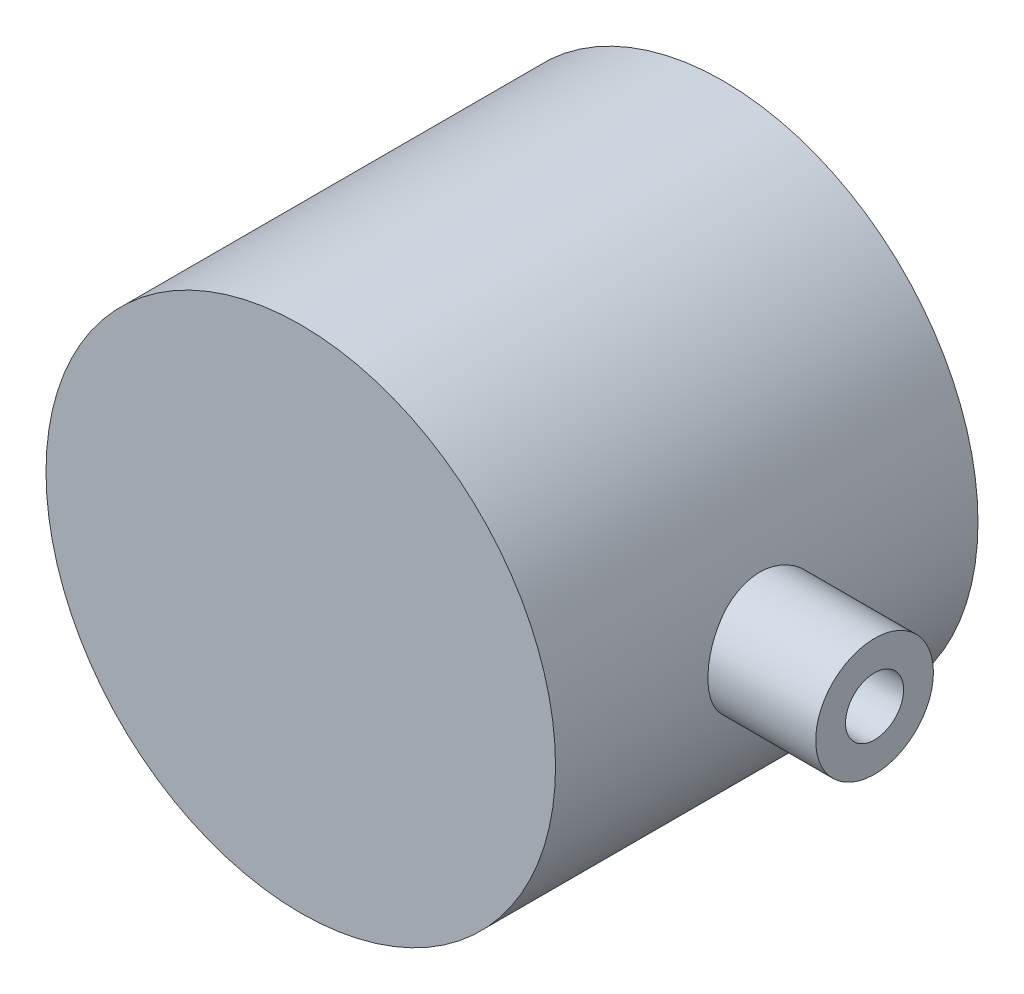
from build123d import *

# Parameters (mm, degrees)
SKETCH1_R                = 24.123
BOSS_EXTRUDE1_DEPTH      = 35
BOSS_EXTRUDE1_DEPTH_BACK = 5
SKETCH2_R                = 3.25
CUT_EXTRUDE2_DEPTH       = 19.25
CUT_EXTRUDE2_DEPTH_BACK  = 19.09
SKETCH4_R                = 3.25
CUT_EXTRUDE3_DEPTH       = 19.09
CUT_EXTRUDE8_START       = -24.123
SKETCH5_R                = 5.25
CUT_EXTRUDE8_DEPTH       = 4.533
CUT_EXTRUDE9_START       = -24.123
SKETCH6_R                = 5.25
CUT_EXTRUDE9_DEPTH       = 4.533
SKETCH7_R                = 17.25
CUT_EXTRUDE10_DEPTH      = 30
CUT_EXTRUDE11_START      = 19.25
SKETCH8_R                = 2.75
CUT_EXTRUDE11_DEPTH      = 24.873
CUT_EXTRUDE11_DEPTH_BACK = 50
BOSS_EXTRUDE2_START      = 23.125
SKETCH9_R                = 5.575
BOSS_EXTRUDE2_DEPTH      = 11.203
CUT_EXTRUDE12_DEPTH      = 50
CUT_EXTRUDE13_START      = -24.125
SKETCH11_R               = 8.25
CUT_EXTRUDE13_DEPTH      = 2
CUT_EXTRUDE14_START      = -24.125
SKETCH12_R               = 8.25
CUT_EXTRUDE14_DEPTH      = 2
SKETCH13_R               = 2.75
CUT_EXTRUDE15_DEPTH      = 30


with BuildPart() as part:
    # Sketch1 → Boss-Extrude1 (new body, two sides)
    with BuildSketch(Plane.XY) as boss_extrude1_sk:
        Circle(SKETCH1_R)
    extrude(amount=BOSS_EXTRUDE1_DEPTH)
    extrude(boss_extrude1_sk.sketch, amount=-BOSS_EXTRUDE1_DEPTH_BACK)

    # Sketch2 → Cut-Extrude2 (cut, two sides)
    with BuildSketch(Plane(origin=(0, 0, 0), x_dir=(0, 0, -1), z_dir=(1, 0, 0))) as cut_extrude2_sk:
        with Locations((-15, 0)):
            Circle(SKETCH2_R)
    extrude(amount=CUT_EXTRUDE2_DEPTH, mode=Mode.SUBTRACT)
    extrude(cut_extrude2_sk.sketch, amount=-CUT_EXTRUDE2_DEPTH_BACK, mode=Mode.SUBTRACT)

    # Sketch4 → Cut-Extrude3 (cut)
    with BuildSketch(Plane(origin=(0, 0, 0), x_dir=(1, 0, 0), z_dir=(0, 1, 0))):
        with Locations((0, -15)):
            Circle(SKETCH4_R)
    extrude(amount=-CUT_EXTRUDE3_DEPTH, mode=Mode.SUBTRACT)

    # Sketch5 → Cut-Extrude8 (cut)
    with BuildSketch(Plane(origin=(0, 0, 0), x_dir=(0, 0, -1), z_dir=(1, 0, 0)).offset(CUT_EXTRUDE8_START)):
        with Locations((-15, 0)):
            Circle(SKETCH5_R)
    extrude(amount=CUT_EXTRUDE8_DEPTH, mode=Mode.SUBTRACT)

    # Sketch6 → Cut-Extrude9 (cut)
    with BuildSketch(Plane(origin=(0, 0, 0), x_dir=(1, 0, 0), z_dir=(0, 1, 0)).offset(CUT_EXTRUDE9_START)):
        with Locations((0, -15)):
            Circle(SKETCH6_R)
    extrude(amount=CUT_EXTRUDE9_DEPTH, mode=Mode.SUBTRACT)

    # Sketch7 → Cut-Extrude10 (cut)
    with BuildSketch(Plane(origin=(0, 0, -5), x_dir=(-1, 0, 0), z_dir=(0, 0, -1))):
        Circle(SKETCH7_R)
    extrude(amount=-CUT_EXTRUDE10_DEPTH, mode=Mode.SUBTRACT)

    # Sketch8 → Cut-Extrude11 (cut, two sides)
    with BuildSketch(Plane(origin=(0, 0, 0), x_dir=(0, 0, -1), z_dir=(1, 0, 0)).offset(CUT_EXTRUDE11_START)) as cut_extrude11_sk:
        with Locations((-15, 0)):
            Circle(SKETCH8_R)
    extrude(amount=CUT_EXTRUDE11_DEPTH, mode=Mode.SUBTRACT)
    extrude(cut_extrude11_sk.sketch, amount=-CUT_EXTRUDE11_DEPTH_BACK, mode=Mode.SUBTRACT)

    # Sketch11 → Cut-Extrude13 (cut)
    with BuildSketch(Plane(origin=(0, 0, 0), x_dir=(0, 0, -1), z_dir=(1, 0, 0)).offset(CUT_EXTRUDE13_START)):
        with Locations((-15, 0)):
            Circle(SKETCH11_R)
    extrude(amount=CUT_EXTRUDE13_DEPTH, mode=Mode.SUBTRACT)

    # Sketch12 → Cut-Extrude14 (cut)
    with BuildSketch(Plane(origin=(0, 0, 0), x_dir=(1, 0, 0), z_dir=(0, 1, 0)).offset(CUT_EXTRUDE14_START)):
        with Locations((0, -15)):
            Circle(SKETCH12_R)
    extrude(amount=CUT_EXTRUDE14_DEPTH, mode=Mode.SUBTRACT)

    # Sketch13 → Cut-Extrude15 (cut)
    with BuildSketch(Plane(origin=(0, 0, 0), x_dir=(1, 0, 0), z_dir=(0, 1, 0))):
        with Locations((0, -15)):
            Circle(SKETCH13_R)
    extrude(amount=-CUT_EXTRUDE15_DEPTH, mode=Mode.SUBTRACT)


with BuildPart() as body_2:
    # Sketch9 → Boss-Extrude2 (new body)
    with BuildSketch(Plane(origin=(0, 0, 0), x_dir=(0, 0, -1), z_dir=(1, 0, 0)).offset(BOSS_EXTRUDE2_START)):
        with Locations((-15, 0)):
            Circle(SKETCH9_R)
    extrude(amount=BOSS_EXTRUDE2_DEPTH)

    # Sketch8 → Cut-Extrude12 (cut)
    with BuildSketch(Plane(origin=(0, 0, 0), x_dir=(0, 0, -1), z_dir=(1, 0, 0))):
        with Locations((-15, 0)):
            Circle(SKETCH8_R)
    extrude(amount=CUT_EXTRUDE12_DEPTH, mode=Mode.SUBTRACT)


solid = Compound([part.part, body_2.part])
